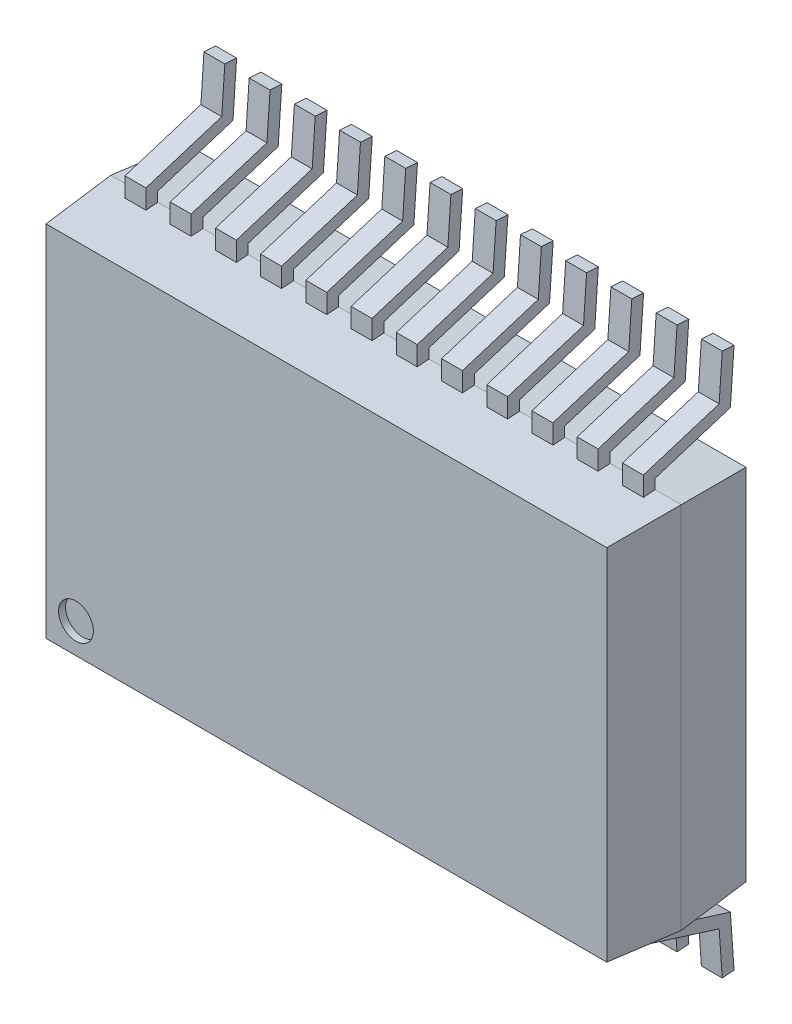
from build123d import *

# Parameters (mm, degrees)
SKETCH1_W             = 8.2
SKETCH1_H             = 5.3
BOSS_EXTRUDE1_DEPTH   = 1
BOSS_EXTRUDE1_TAPER   = 4
EXTRUDE_THIN1_DEPTH   = 0.15
LPATTERN1_COUNT       = 12
LPATTERN1_PITCH       = 0.65
MIRROR2_COPY_1_DEPTH  = 0.15
MIRROR2_COPY_2_DEPTH  = 0.15
MIRROR2_COPY_3_DEPTH  = 0.15
MIRROR2_COPY_4_DEPTH  = 0.15
MIRROR2_COPY_5_DEPTH  = 0.15
MIRROR2_COPY_6_DEPTH  = 0.15
MIRROR2_COPY_7_DEPTH  = 0.15
MIRROR2_COPY_8_DEPTH  = 0.15
MIRROR2_COPY_9_DEPTH  = 0.15
MIRROR2_COPY_10_DEPTH = 0.15
MIRROR2_COPY_11_DEPTH = 0.15
SKETCH3_R             = 0.25
CUT_EXTRUDE1_DEPTH    = 0.1


with BuildPart() as part:
    # Sketch1 → Boss-Extrude1 (new body)
    with BuildSketch(Plane.XY):
        with Locations((4.1, 2.65)):
            Rectangle(SKETCH1_W, SKETCH1_H)
    boss_extrude1 = extrude(amount=BOSS_EXTRUDE1_DEPTH, taper=BOSS_EXTRUDE1_TAPER)

    # Mirror1: Boss-Extrude1 across plane
    add(boss_extrude1.mirror(Plane.XY))


with BuildPart() as body_2:
    # Sketch2 → Extrude-Thin1 (new body, symmetric)
    with BuildSketch(Plane(origin=(0.525, 0, 0), x_dir=(0, 0, -1), z_dir=(1, 0, 0))):
        Polygon((0, 0), (0, -0.160970504), (1.081511455, -0.5), (1.133956564, -1.25), (0.964370676, -1.261858601), (0.920014192, -0.627531335), (-0.17, -0.285836421), (-0.17, 0), align=None)
    extrude_thin1 = extrude(amount=EXTRUDE_THIN1_DEPTH, both=True)


with BuildPart() as lpattern1_1:
    # LPattern1: Extrude-Thin1 ×12
    with Locations(*[(i * LPATTERN1_PITCH, 0, 0) for i in range(1, LPATTERN1_COUNT)]):
        add(extrude_thin1)


with BuildPart() as part_1:
    add(part.part)

    # Mirror2: Extrude-Thin1 across plane
    add(extrude_thin1.mirror(Plane.ZX.offset(2.64)))

    # Mirror2 copy 1 sketch → Mirror2 copy 1 (add, symmetric)
    with BuildSketch(Plane(origin=(1.175, 5.28, 0), x_dir=(0, 0, -1), z_dir=(1, 0, 0))):
        Polygon((0, 0), (0, 0.160970504), (1.081511455, 0.5), (1.133956564, 1.25), (0.964370676, 1.261858601), (0.920014192, 0.627531335), (-0.17, 0.285836421), (-0.17, 0), align=None)
    extrude(amount=MIRROR2_COPY_1_DEPTH, both=True)

    # Mirror2 copy 2 sketch → Mirror2 copy 2 (add, symmetric)
    with BuildSketch(Plane(origin=(1.825, 5.28, 0), x_dir=(0, 0, -1), z_dir=(1, 0, 0))):
        Polygon((0, 0), (0, 0.160970504), (1.081511455, 0.5), (1.133956564, 1.25), (0.964370676, 1.261858601), (0.920014192, 0.627531335), (-0.17, 0.285836421), (-0.17, 0), align=None)
    extrude(amount=MIRROR2_COPY_2_DEPTH, both=True)

    # Mirror2 copy 3 sketch → Mirror2 copy 3 (add, symmetric)
    with BuildSketch(Plane(origin=(2.475, 5.28, 0), x_dir=(0, 0, -1), z_dir=(1, 0, 0))):
        Polygon((0, 0), (0, 0.160970504), (1.081511455, 0.5), (1.133956564, 1.25), (0.964370676, 1.261858601), (0.920014192, 0.627531335), (-0.17, 0.285836421), (-0.17, 0), align=None)
    extrude(amount=MIRROR2_COPY_3_DEPTH, both=True)

    # Mirror2 copy 4 sketch → Mirror2 copy 4 (add, symmetric)
    with BuildSketch(Plane(origin=(3.125, 5.28, 0), x_dir=(0, 0, -1), z_dir=(1, 0, 0))):
        Polygon((0, 0), (0, 0.160970504), (1.081511455, 0.5), (1.133956564, 1.25), (0.964370676, 1.261858601), (0.920014192, 0.627531335), (-0.17, 0.285836421), (-0.17, 0), align=None)
    extrude(amount=MIRROR2_COPY_4_DEPTH, both=True)

    # Mirror2 copy 5 sketch → Mirror2 copy 5 (add, symmetric)
    with BuildSketch(Plane(origin=(3.775, 5.28, 0), x_dir=(0, 0, -1), z_dir=(1, 0, 0))):
        Polygon((0, 0), (0, 0.160970504), (1.081511455, 0.5), (1.133956564, 1.25), (0.964370676, 1.261858601), (0.920014192, 0.627531335), (-0.17, 0.285836421), (-0.17, 0), align=None)
    extrude(amount=MIRROR2_COPY_5_DEPTH, both=True)

    # Mirror2 copy 6 sketch → Mirror2 copy 6 (add, symmetric)
    with BuildSketch(Plane(origin=(4.425, 5.28, 0), x_dir=(0, 0, -1), z_dir=(1, 0, 0))):
        Polygon((0, 0), (0, 0.160970504), (1.081511455, 0.5), (1.133956564, 1.25), (0.964370676, 1.261858601), (0.920014192, 0.627531335), (-0.17, 0.285836421), (-0.17, 0), align=None)
    extrude(amount=MIRROR2_COPY_6_DEPTH, both=True)

    # Mirror2 copy 7 sketch → Mirror2 copy 7 (add, symmetric)
    with BuildSketch(Plane(origin=(5.075, 5.28, 0), x_dir=(0, 0, -1), z_dir=(1, 0, 0))):
        Polygon((0, 0), (0, 0.160970504), (1.081511455, 0.5), (1.133956564, 1.25), (0.964370676, 1.261858601), (0.920014192, 0.627531335), (-0.17, 0.285836421), (-0.17, 0), align=None)
    extrude(amount=MIRROR2_COPY_7_DEPTH, both=True)

    # Mirror2 copy 8 sketch → Mirror2 copy 8 (add, symmetric)
    with BuildSketch(Plane(origin=(5.725, 5.28, 0), x_dir=(0, 0, -1), z_dir=(1, 0, 0))):
        Polygon((0, 0), (0, 0.160970504), (1.081511455, 0.5), (1.133956564, 1.25), (0.964370676, 1.261858601), (0.920014192, 0.627531335), (-0.17, 0.285836421), (-0.17, 0), align=None)
    extrude(amount=MIRROR2_COPY_8_DEPTH, both=True)

    # Mirror2 copy 9 sketch → Mirror2 copy 9 (add, symmetric)
    with BuildSketch(Plane(origin=(6.375, 5.28, 0), x_dir=(0, 0, -1), z_dir=(1, 0, 0))):
        Polygon((0, 0), (0, 0.160970504), (1.081511455, 0.5), (1.133956564, 1.25), (0.964370676, 1.261858601), (0.920014192, 0.627531335), (-0.17, 0.285836421), (-0.17, 0), align=None)
    extrude(amount=MIRROR2_COPY_9_DEPTH, both=True)

    # Mirror2 copy 10 sketch → Mirror2 copy 10 (add, symmetric)
    with BuildSketch(Plane(origin=(7.025, 5.28, 0), x_dir=(0, 0, -1), z_dir=(1, 0, 0))):
        Polygon((0, 0), (0, 0.160970504), (1.081511455, 0.5), (1.133956564, 1.25), (0.964370676, 1.261858601), (0.920014192, 0.627531335), (-0.17, 0.285836421), (-0.17, 0), align=None)
    extrude(amount=MIRROR2_COPY_10_DEPTH, both=True)

    # Mirror2 copy 11 sketch → Mirror2 copy 11 (add, symmetric)
    with BuildSketch(Plane(origin=(7.675, 5.28, 0), x_dir=(0, 0, -1), z_dir=(1, 0, 0))):
        Polygon((0, 0), (0, 0.160970504), (1.081511455, 0.5), (1.133956564, 1.25), (0.964370676, 1.261858601), (0.920014192, 0.627531335), (-0.17, 0.285836421), (-0.17, 0), align=None)
    extrude(amount=MIRROR2_COPY_11_DEPTH, both=True)

    # Sketch3 → Cut-Extrude1 (cut)
    with BuildSketch(Plane.XY.offset(1)):
        with Locations((0.5, 0.5)):
            Circle(SKETCH3_R)
    extrude(amount=-CUT_EXTRUDE1_DEPTH, mode=Mode.SUBTRACT)


solid = Compound([body_2.part, lpattern1_1.part, part_1.part])
